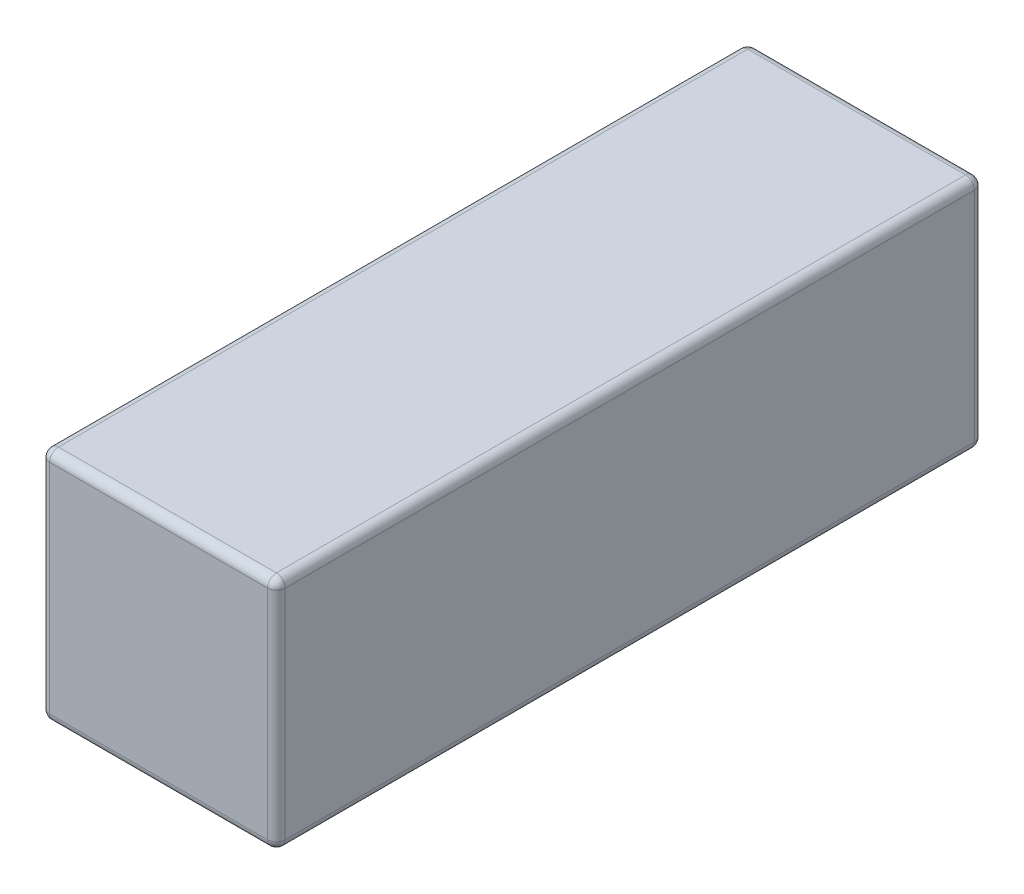
from build123d import *

# Parameters (mm, degrees)
SKETCH3_W                = 4
SKETCH3_H                = 4
BOSS_EXTRUDE1_DEPTH      = 6
BOSS_EXTRUDE1_DEPTH_BACK = 6
FILLET2_R                = 0.15


with BuildPart() as part:
    # Sketch3 → Boss-Extrude1 (new body, two sides)
    with BuildSketch(Plane.XY) as boss_extrude1_sk:
        Rectangle(SKETCH3_W, SKETCH3_H)
    extrude(amount=BOSS_EXTRUDE1_DEPTH)
    extrude(boss_extrude1_sk.sketch, amount=-BOSS_EXTRUDE1_DEPTH_BACK)

    # Fillet2
    fillet2_edges = [part.edges().sort_by_distance(p)[0] for p in [
        (0, 2, 6),
        (0, -2, -6),
        (-2, 0, -6),
        (0, 2, -6),
        (2, 0, -6),
        (-2, 0, 6),
        (0, -2, 6),
        (2, 0, 6),
        (-2, -2, 0),
        (-2, 2, 0),
        (2, 2, 0),
        (2, -2, 0),
    ]]
    fillet(fillet2_edges, radius=FILLET2_R)


solid = part.part
